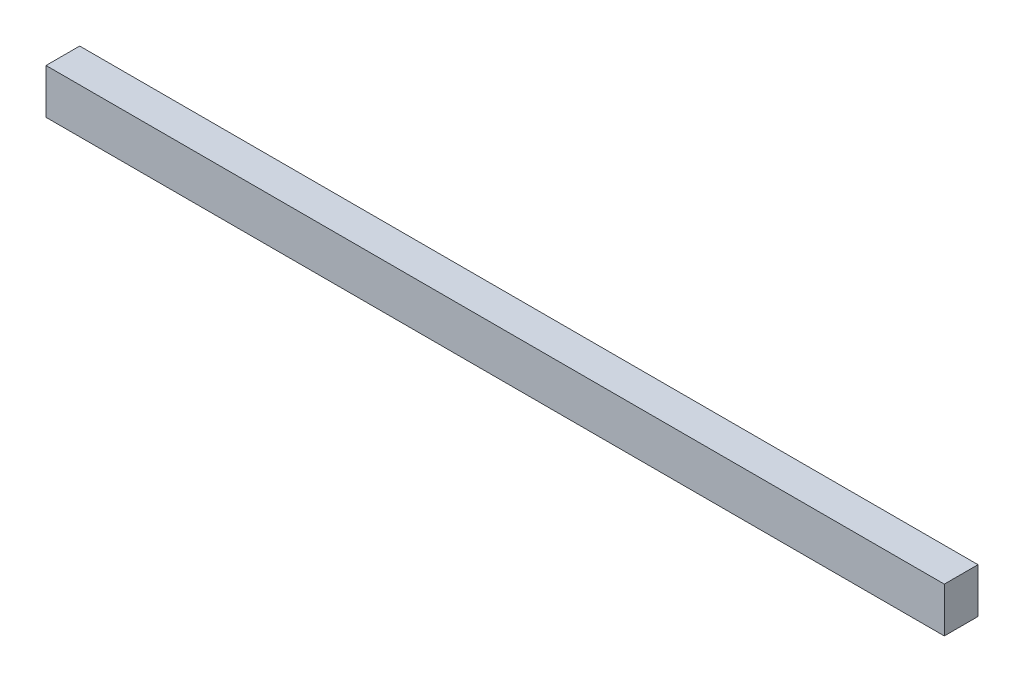
from build123d import *

# Parameters (mm, degrees)
SKETCH1_W           = 508
SKETCH1_H           = 25.4
BOSS_EXTRUDE1_DEPTH = 19.05


with BuildPart() as part:
    # Sketch1 → Boss-Extrude1 (new body)
    with BuildSketch(Plane.XY):
        with Locations((254, 12.7)):
            Rectangle(SKETCH1_W, SKETCH1_H)
    extrude(amount=-BOSS_EXTRUDE1_DEPTH)


solid = part.part
